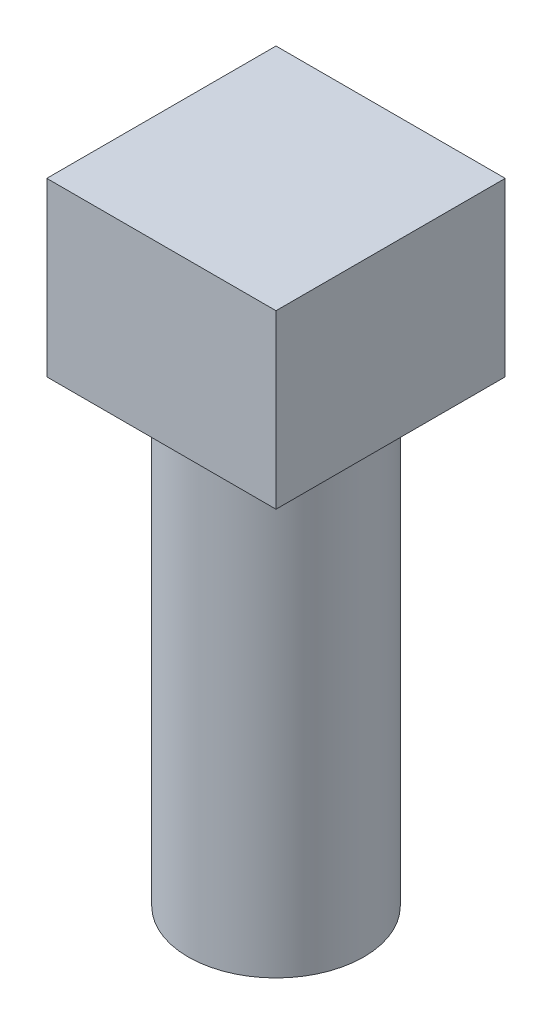
from build123d import *

# Parameters (mm, degrees)
SKETCH1_R           = 5.842
BOSS_EXTRUDE1_DEPTH = 30.48
SKETCH2_W           = 15.24
SKETCH2_H           = 15.24
BOSS_EXTRUDE2_DEPTH = 11.43


with BuildPart() as part:
    # Sketch1 → Boss-Extrude1 (new body)
    with BuildSketch(Plane(origin=(0, 0, 0), x_dir=(1, 0, 0), z_dir=(0, 1, 0))):
        Circle(SKETCH1_R)
    extrude(amount=BOSS_EXTRUDE1_DEPTH)

    # Sketch2 → Boss-Extrude2 (add)
    with BuildSketch(Plane(origin=(0, 30.48, 0), x_dir=(1, 0, 0), z_dir=(0, 1, 0))):
        Rectangle(SKETCH2_W, SKETCH2_H)
    extrude(amount=BOSS_EXTRUDE2_DEPTH)


solid = part.part
